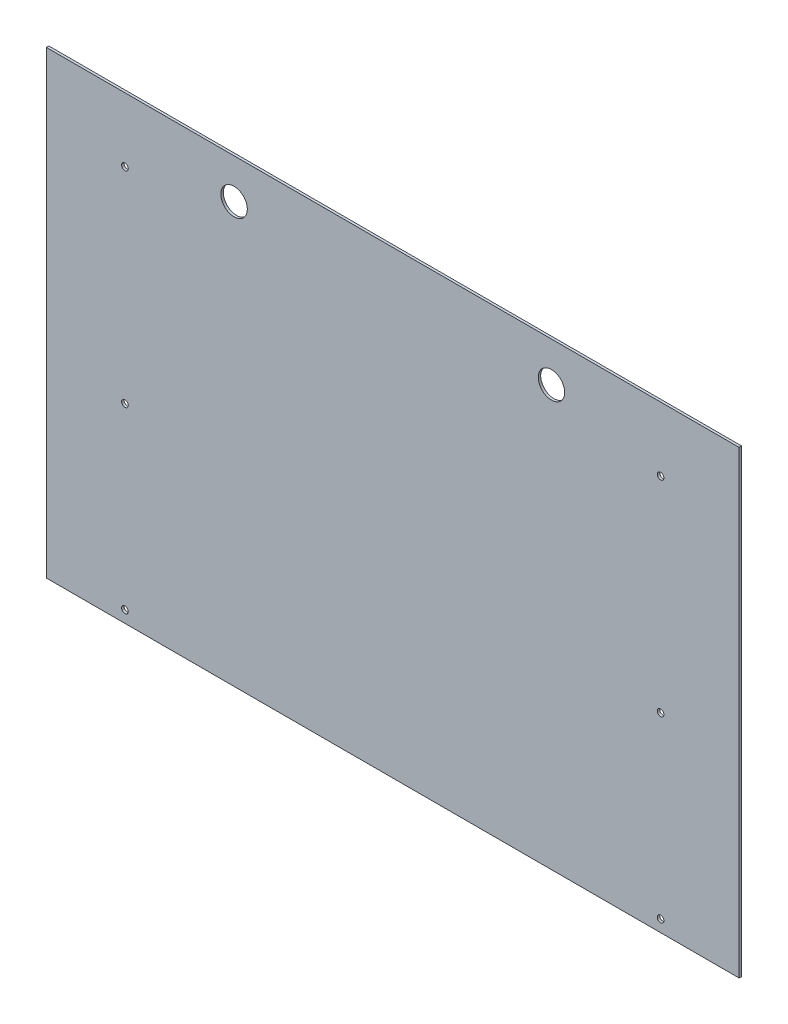
from build123d import *

# Parameters (mm, degrees)
SKETCH1_W          = 1330.325
SKETCH1_H          = 882.65
EXTRUDE1_DEPTH     = 4.7625
SKETCH2_R          = 6.35
CUT_EXTRUDE1_DEPTH = 5.7625
SKETCH3_R          = 25.4
CUT_EXTRUDE2_DEPTH = 5.7625


with BuildPart() as part:
    # Sketch1 → Extrude1 (new body)
    with BuildSketch(Plane.XY):
        with Locations((0, 638.175)):
            Rectangle(SKETCH1_W, SKETCH1_H)
    extrude(amount=EXTRUDE1_DEPTH)

    # Sketch2 → Cut-Extrude1 (cut, through all)
    with BuildSketch(Plane.XY.offset(4.7625)):
        with Locations((514.35, 956.31)):
            Circle(SKETCH2_R)
        with Locations((514.35, 562.61)):
            Circle(SKETCH2_R)
        with Locations((514.35, 219.71)):
            Circle(SKETCH2_R)
        with Locations((-514.35, 219.71)):
            Circle(SKETCH2_R)
        with Locations((-514.35, 562.61)):
            Circle(SKETCH2_R)
        with Locations((-514.35, 956.31)):
            Circle(SKETCH2_R)
    extrude(amount=-CUT_EXTRUDE1_DEPTH, mode=Mode.SUBTRACT)

    # Sketch3 → Cut-Extrude2 (cut, through all)
    with BuildSketch(Plane.XY.offset(4.7625)):
        with Locations((304.8, 1003.3)):
            Circle(SKETCH3_R)
        with Locations((-304.8, 1003.3)):
            Circle(SKETCH3_R)
    extrude(amount=-CUT_EXTRUDE2_DEPTH, mode=Mode.SUBTRACT)


solid = part.part
